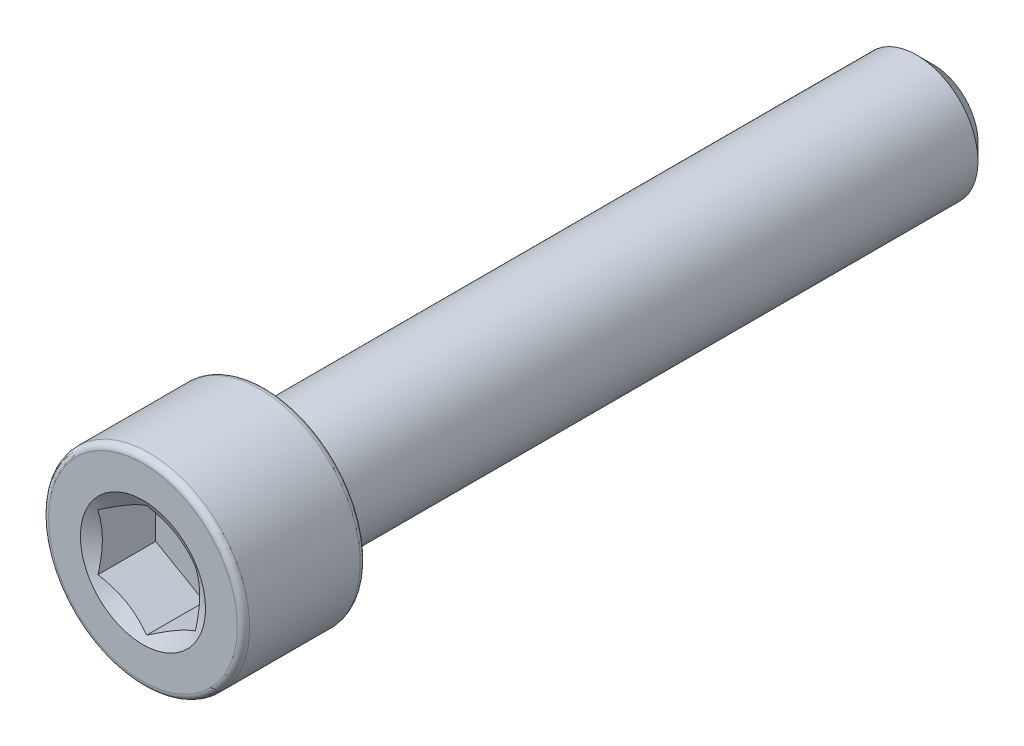
from build123d import *

# Parameters (mm, degrees)
CUT_EXTRUDE1_START = 11.2776
CUT_EXTRUDE1_DEPTH = 1.7526


with BuildPart() as part:
    # Sketch2 → Revolve1 (revolve)
    with BuildSketch(Plane(origin=(0, 0, 0), x_dir=(0, 0, -1), z_dir=(1, 0, 0)), mode=Mode.PRIVATE) as revolve1_sk:
        with BuildLine():
            Line((11.2776, 0), (11.2776, 1.27635))
            Line((11.2776, 1.27635), (10.80135, 1.7526))
            Line((10.80135, 1.7526), (-7.7724, 1.7526))
            Line((-7.7724, 1.7526), (-7.7724, 2.69494))
            ThreePointArc((-7.7724, 2.69494), (-7.823732466, 2.818867534), (-7.94766, 2.8702))
            Line((-7.94766, 2.8702), (-11.10234, 2.8702))
            ThreePointArc((-11.10234, 2.8702), (-11.226267534, 2.818867534), (-11.2776, 2.69494))
            Line((-11.2776, 2.69494), (-11.2776, 0))
            Line((-11.2776, 0), (11.2776, 0))
        make_face()
    revolve(revolve1_sk.sketch.rotate(Axis((0, 0, -11.2776), (0, 0, 1)), 90), axis=Axis((0, 0, -11.2776), (0, 0, 1)))

    # Sketch3 → Cut-Extrude1 (cut)
    with BuildSketch(Plane.XY.offset(CUT_EXTRUDE1_START)):
        Polygon((-1.3890625, 0.801975608), (-1.3890625, -0.801975608), (0, -1.603951217), (1.3890625, -0.801975608), (1.3890625, 0.801975608), (0, 1.603951217), align=None)
    extrude(amount=-CUT_EXTRUDE1_DEPTH, mode=Mode.SUBTRACT)

    # Cut-Extrude2 cone 1 section (through the dimple's axis) → Cut-Extrude2 (revolve, cut)
    with BuildSketch(Plane(origin=(0, 0, 11.2776), x_dir=(0, -1, 0), z_dir=(1, 0, 0))):
        Polygon((0, 0), (1.78578268, 0), (0, 1.031022111), align=None)
    revolve(axis=Axis((0, 0, 11.2776), (0, 0, -1)), mode=Mode.SUBTRACT)


solid = part.part
